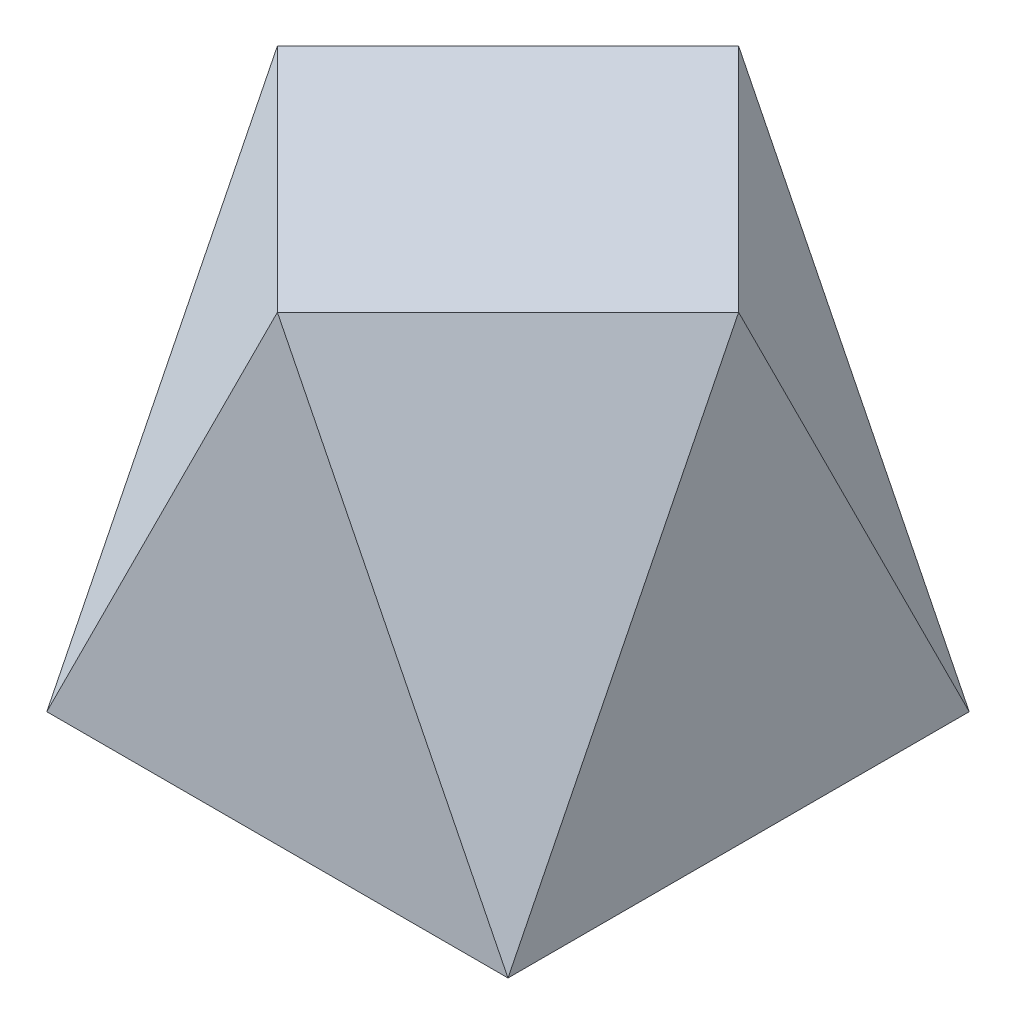
from build123d import *

# Parameters (mm, degrees)
SKETCH1_W           = 4
SKETCH1_H           = 4
BOSS_EXTRUDE1_DEPTH = 4
CUT_EXTRUDE1_DEPTH  = 4
CUT_EXTRUDE3_DEPTH  = 4
CUT_EXTRUDE5_DEPTH  = 4
CUT_EXTRUDE6_DEPTH  = 4


with BuildPart() as part:
    # Sketch1 → Boss-Extrude1 (new body)
    with BuildSketch(Plane(origin=(0, 0, 0), x_dir=(1, 0, 0), z_dir=(0, 1, 0))):
        Rectangle(SKETCH1_W, SKETCH1_H)
    extrude(amount=BOSS_EXTRUDE1_DEPTH)

    # 3DSketch1 → Cut-Extrude1 (cut, along a direction that is not the sketch's normal)
    with BuildSketch(Plane(origin=(-2, 0, 2), x_dir=(0.447213595499958, 0.894427190999916, 0), z_dir=(-0.6666666666666667, 0.33333333333333337, 0.6666666666666667))):
        Polygon((0, 0), (4.472135955, 0), (3.577708764, 2.683281573), align=None)
    extrude(amount=CUT_EXTRUDE1_DEPTH, dir=(-1, 0, 0), mode=Mode.SUBTRACT)

    # 3DSketch2 → Cut-Extrude3 (cut, along a direction that is not the sketch's normal)
    with BuildSketch(Plane(origin=(0, 4, 2), x_dir=(0.447213595499958, -0.894427190999916, 0), z_dir=(0.6666666666666667, 0.33333333333333337, 0.6666666666666667))):
        Polygon((0, 0), (4.472135955, 0), (0.894427191, 2.683281573), align=None)
    extrude(amount=CUT_EXTRUDE3_DEPTH, dir=(1, 0, 0), mode=Mode.SUBTRACT)

    # 3DSketch3 → Cut-Extrude5 (cut, along a direction that is not the sketch's normal)
    with BuildSketch(Plane(origin=(2, 0, -2), x_dir=(0, 0.894427190999916, 0.4472135954999579), z_dir=(-0.6666666666666666, -0.3333333333333333, 0.6666666666666667))):
        Polygon((0, 0), (4.472135955, 0), (3.577708764, 2.683281573), align=None)
    extrude(amount=-CUT_EXTRUDE5_DEPTH, dir=(0, 0, 1), mode=Mode.SUBTRACT)

    # 3DSketch4 → Cut-Extrude6 (cut, along a direction that is not the sketch's normal)
    with BuildSketch(Plane(origin=(0, 4, -2), x_dir=(-0.45428866888855013, -0.8908545365655772, 0), z_dir=(-0.6651833322407542, 0.3392082973899275, -0.6651833322407539))):
        Polygon((0, 0), (4.40248709, 0), (0.908577338, 2.678523328), align=None)
    extrude(amount=CUT_EXTRUDE6_DEPTH, dir=(-1, 0, 0), mode=Mode.SUBTRACT)


solid = part.part
